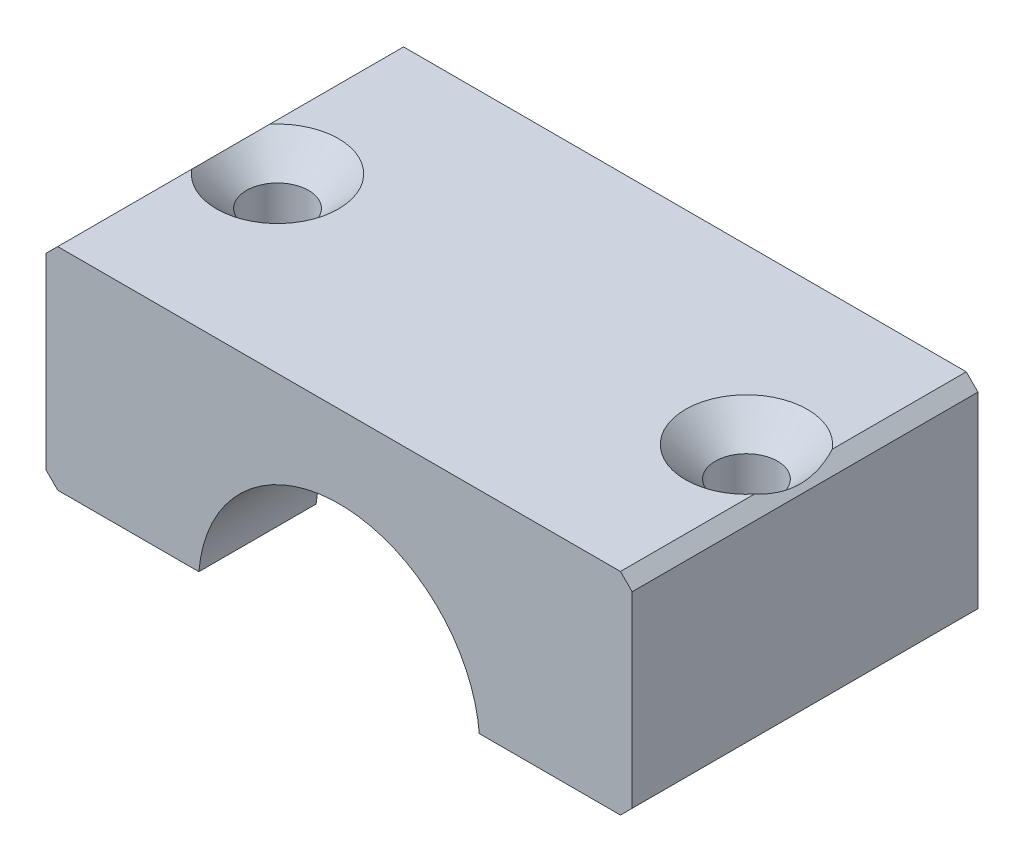
from build123d import *

# Parameters (mm, degrees)
BOSS_EXTRUDE1_DEPTH         = 29.5
CHAMFER1_SIZE               = 1
SKETCH4_W                   = 10.79057785
SKETCH4_H                   = 9.5
HOLE_WIZARD_M51_D           = 5.3
HOLE_WIZARD_M51_CSINK_D     = 10.4
HOLE_WIZARD_M51_CSINK_ANGLE = 90


with BuildPart() as part:
    # Sketch2 → Boss-Extrude1 (new body)
    with BuildSketch(Plane.XY):
        with BuildLine():
            Line((11.958260743, 1), (25, 1))
            Line((25, 1), (25, 19))
            Line((25, 19), (-25, 19))
            Line((-25, 19), (-25, 1))
            Line((-25, 1), (-11.958260743, 1))
            ThreePointArc((-11.958260743, 1), (0, 12), (11.958260743, 1))
        make_face()
    extrude(amount=BOSS_EXTRUDE1_DEPTH)

    # Chamfer1
    chamfer1_edges = [part.edges().sort_by_distance(p)[0] for p in [
        (-25, 19, 14.75),
        (25, 19, 14.75),
        (25, 1, 14.75),
        (-25, 1, 14.75),
    ]]
    chamfer(chamfer1_edges, length=CHAMFER1_SIZE)

    # Sketch4 → Cut-Revolve1 (revolve, cut)
    with BuildSketch(Plane(origin=(0, 0, 0), x_dir=(-1, 0, 0), z_dir=(0, -1, 0))):
        with Locations((9.604711075, -14.75)):
            Rectangle(SKETCH4_W, SKETCH4_H)
    revolve(axis=Axis((0, 0, 0), (0, 0, 1)), mode=Mode.SUBTRACT)

    # Зенковка для  винта с плоской головкой M51 (through all)
    with Locations(Plane(origin=(0, 19, 0), x_dir=(1, 0, 0), z_dir=(0, 1, 0))):
        with Locations((-20, -14.75), (20, -14.75)):
            CounterSinkHole(HOLE_WIZARD_M51_D / 2, HOLE_WIZARD_M51_CSINK_D / 2, counter_sink_angle=HOLE_WIZARD_M51_CSINK_ANGLE)


solid = part.part
